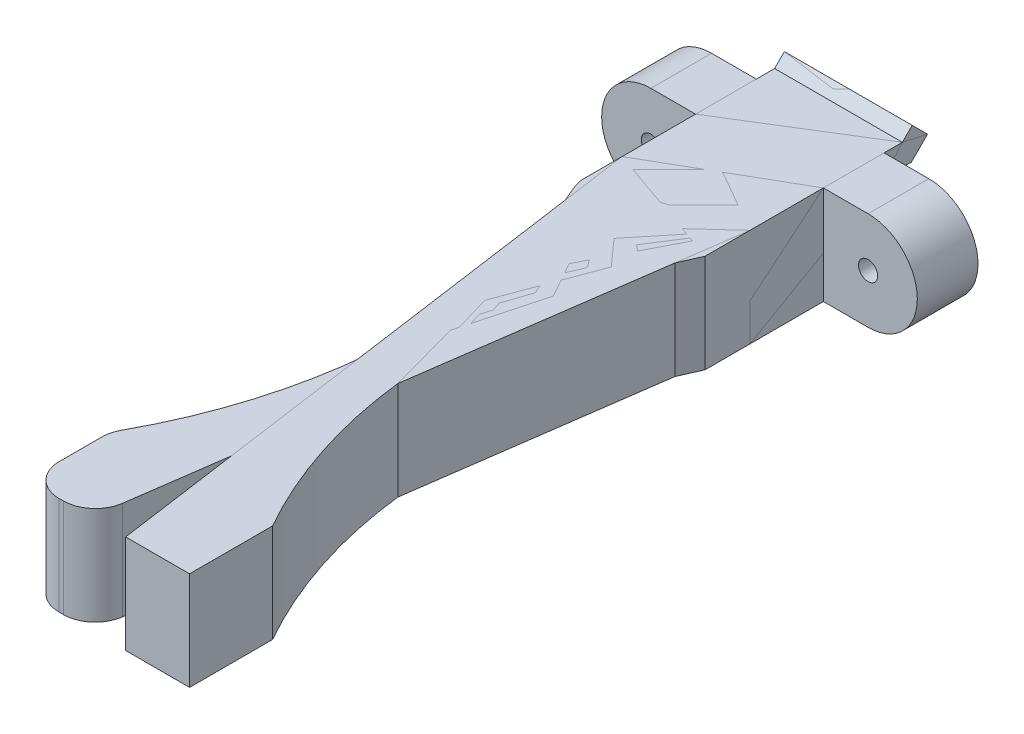
from build123d import *

# Parameters (mm, degrees)
SKETCH2_W           = 10
SKETCH2_H           = 14.768412439
BOSS_EXTRUDE1_DEPTH = 5
BOSS_EXTRUDE4_DEPTH = 10
SKETCH9_W           = 10
SKETCH9_H           = 3.18
SKETCH9_H_2         = 3.888412439
CUT_EXTRUDE3_DEPTH  = 5
BOSS_EXTRUDE5_DEPTH = 7.7
SKETCH12_R          = 0.75
BOSS_EXTRUDE7_DEPTH = 4.75
FILLET1_R           = 2.5


with BuildPart() as part:
    # Sketch2 → Boss-Extrude1 (new body)
    with BuildSketch(Plane.XY):
        with Locations((0, 1.566049366)):
            Rectangle(SKETCH2_W, SKETCH2_H)
    extrude(amount=BOSS_EXTRUDE1_DEPTH)

    # Sketch8 → Boss-Extrude4 (add)
    with BuildSketch(Plane.ZY.offset(5)):
        Polygon((-0.15, 5.770255585), (0, 5.770255585), (0, 4.070255585), (-0.15, 4.070255585), (-2.137867966, 4.070255585), (-3.402081528, 5.334469147), (-2.2, 6.536550675), (-1.43370491, 5.770255585), align=None)
        Polygon((-0.15, -1.929744415), (0, -1.929744415), (0, -0.229744415), (-0.15, -0.229744415), (-1.43370491, -0.229744415), (-2.2, 0.536550675), (-3.402081528, -0.665530853), (-2.137867966, -1.929744415), align=None)
    extrude(amount=-BOSS_EXTRUDE4_DEPTH)

    # Sketch9 → Cut-Extrude3 (cut)
    with BuildSketch(Plane(origin=(0, 0, 0), x_dir=(-1, 0, 0), z_dir=(0, 0, -1))):
        with Locations((0, 7.360255585)):
            Rectangle(SKETCH9_W, SKETCH9_H)
        with Locations((0, -3.873950635)):
            Rectangle(SKETCH9_W, SKETCH9_H_2)
    extrude(amount=-CUT_EXTRUDE3_DEPTH, mode=Mode.SUBTRACT)

    # Sketch10 → Boss-Extrude5 (add)
    with BuildSketch(Plane(origin=(0, 5.770255585, 0), x_dir=(1, 0, 0), z_dir=(0, 1, 0))):
        with BuildLine():
            Line((-5, -5), (-5, -10.5))
            Line((-5, -10.5), (1.352445729, -55.7))
            Line((1.352445729, -55.7), (6.352445729, -55.7))
            Line((6.352445729, -55.7), (6.352445729, -49.2))
            ThreePointArc((6.352445729, -49.2), (1.383429579, -31.764936646), (5, -14))
            Line((5, -14), (5, -5))
            Line((5, -5), (-5, -5))
        make_face()
    extrude(amount=-BOSS_EXTRUDE5_DEPTH)

    # Sketch12 → Boss-Extrude7 (add)
    with BuildSketch(Plane.XY):
        with BuildLine():
            Line((5, 5.770255585), (8.5, 5.770255585))
            ThreePointArc((8.5, 5.770255585), (12.35, 1.920255585), (8.5, -1.929744415))
            Line((8.5, -1.929744415), (5, -1.929744415))
            Line((5, -1.929744415), (5, 5.770255585))
        make_face()
        with Locations((8.5, 1.920255585)):
            Circle(SKETCH12_R, mode=Mode.SUBTRACT)
    extrude(amount=BOSS_EXTRUDE7_DEPTH)


with BuildPart() as body_2:
    # Mirror1: mirrored copy
    add(part.part.mirror(Plane(origin=(0, 0, 0), x_dir=(0, 0, 1), z_dir=(1, 0, 0))))

    # Fillet1
    fillet1_edges = [body_2.edges().sort_by_distance(p)[0] for p in [
        (-6.352445729, 1.920255585, 49.2),
        (-5, 1.920255585, 14),
        (-1.352445729, 1.920255585, 55.7),
        (-6.352445729, 1.920255585, 55.7),
    ]]
    fillet(fillet1_edges, radius=FILLET1_R)


solid = Compound([part.part, body_2.part])
